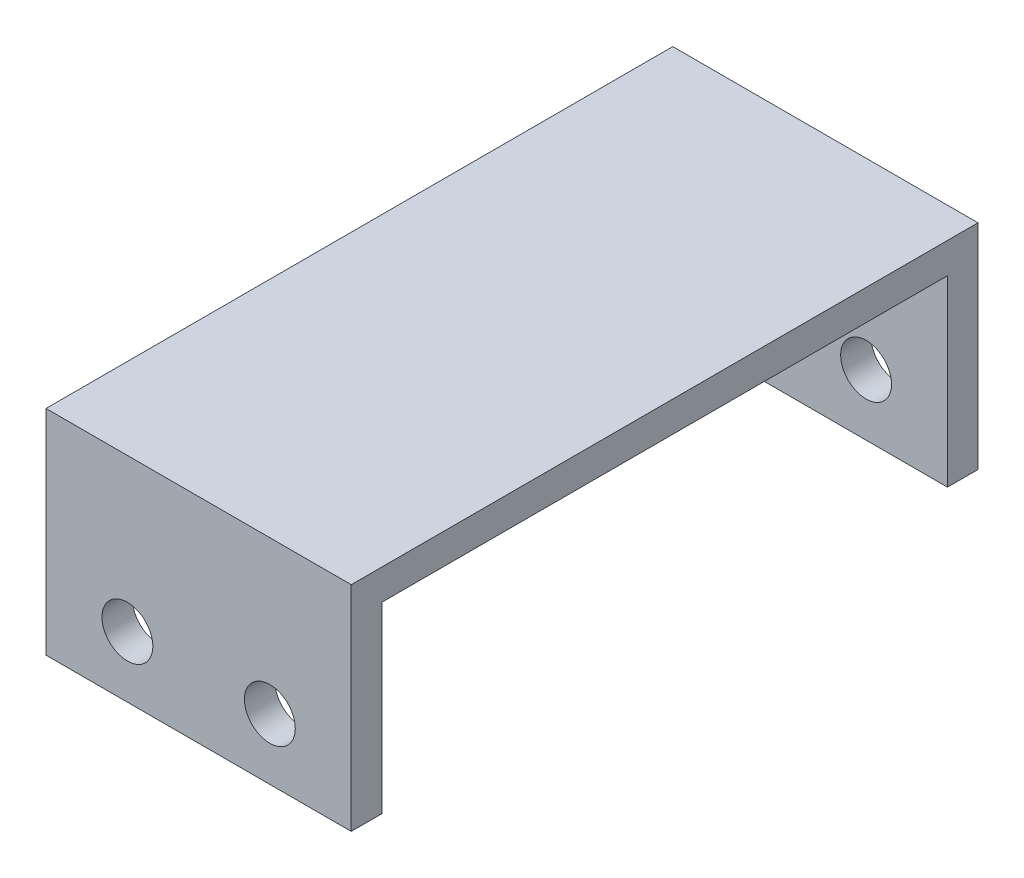
from build123d import *

# Parameters (mm, degrees)
SKETCH_1_W               = 15
SKETCH_1_H               = 30.8
EXTRUDE_1_DEPTH          = 1.5
SKETCH_2_W               = 15
SKETCH_2_H               = 1.5
EXTRUDE_2_DEPTH          = 9
SKETCH_3_R               = 1.25
CUT_EXTRUDE_1_DEPTH      = 1
CUT_EXTRUDE_1_DEPTH_BACK = 31.8


with BuildPart() as part:
    # 草图1 → 凸台-拉伸1 (new body)
    with BuildSketch(Plane(origin=(0, 0, 0), x_dir=(1, 0, 0), z_dir=(0, 1, 0))):
        with Locations((-5.581761006, 1.950314465)):
            Rectangle(SKETCH_1_W, SKETCH_1_H)
    extrude(amount=EXTRUDE_1_DEPTH)

    # 草图2 → 凸台-拉伸2 (add)
    with BuildSketch(Plane.XZ):
        with Locations((-5.581761006, 12.699685535)):
            Rectangle(SKETCH_2_W, SKETCH_2_H)
        with Locations((-5.581761006, -16.600314465)):
            Rectangle(SKETCH_2_W, SKETCH_2_H)
    extrude(amount=EXTRUDE_2_DEPTH)

    # 草图3 → 切除-拉伸1 (cut, two sides)
    with BuildSketch(Plane.XY.offset(13.449685535)) as cut_extrude_1_sk:
        with Locations((-9.081761006, -6)):
            Circle(SKETCH_3_R)
        with Locations((-2.081761006, -6)):
            Circle(SKETCH_3_R)
    extrude(amount=CUT_EXTRUDE_1_DEPTH, mode=Mode.SUBTRACT)
    extrude(cut_extrude_1_sk.sketch, amount=-CUT_EXTRUDE_1_DEPTH_BACK, mode=Mode.SUBTRACT)


solid = part.part
